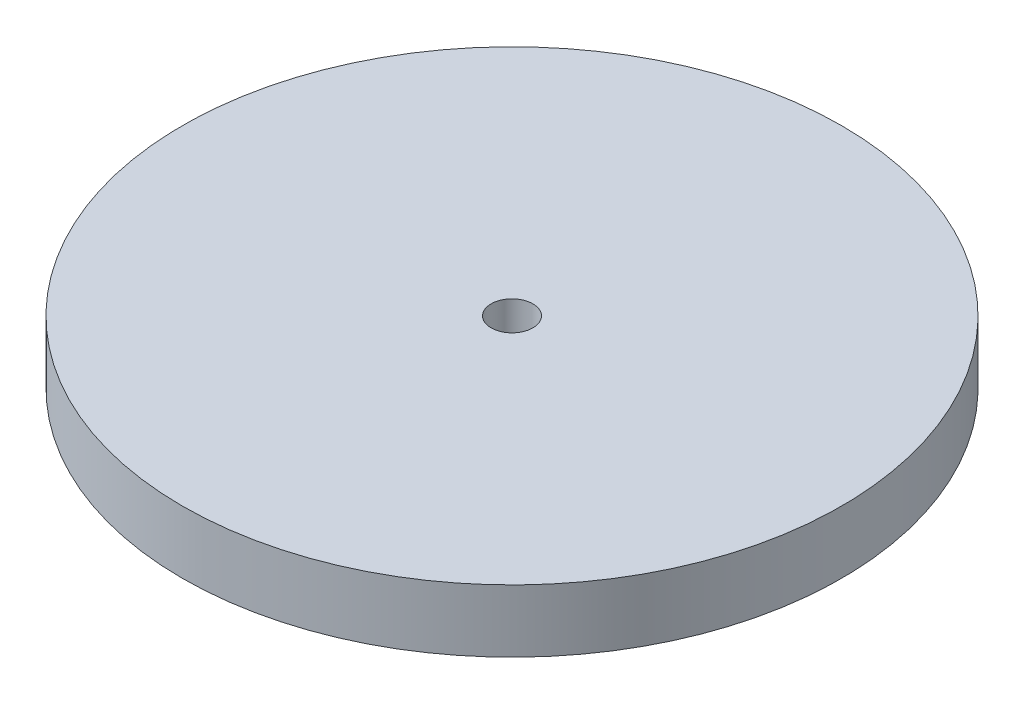
from build123d import *

# Parameters (mm, degrees)
SKETCH1_R           = 157.89
SKETCH1_R_2         = 10
BOSS_EXTRUDE1_DEPTH = 30


with BuildPart() as part:
    # Sketch1 → Boss-Extrude1 (new body)
    with BuildSketch(Plane(origin=(0, 0, 0), x_dir=(1, 0, 0), z_dir=(0, 1, 0))):
        Circle(SKETCH1_R)
        Circle(SKETCH1_R_2, mode=Mode.SUBTRACT)
    extrude(amount=BOSS_EXTRUDE1_DEPTH)


solid = part.part
